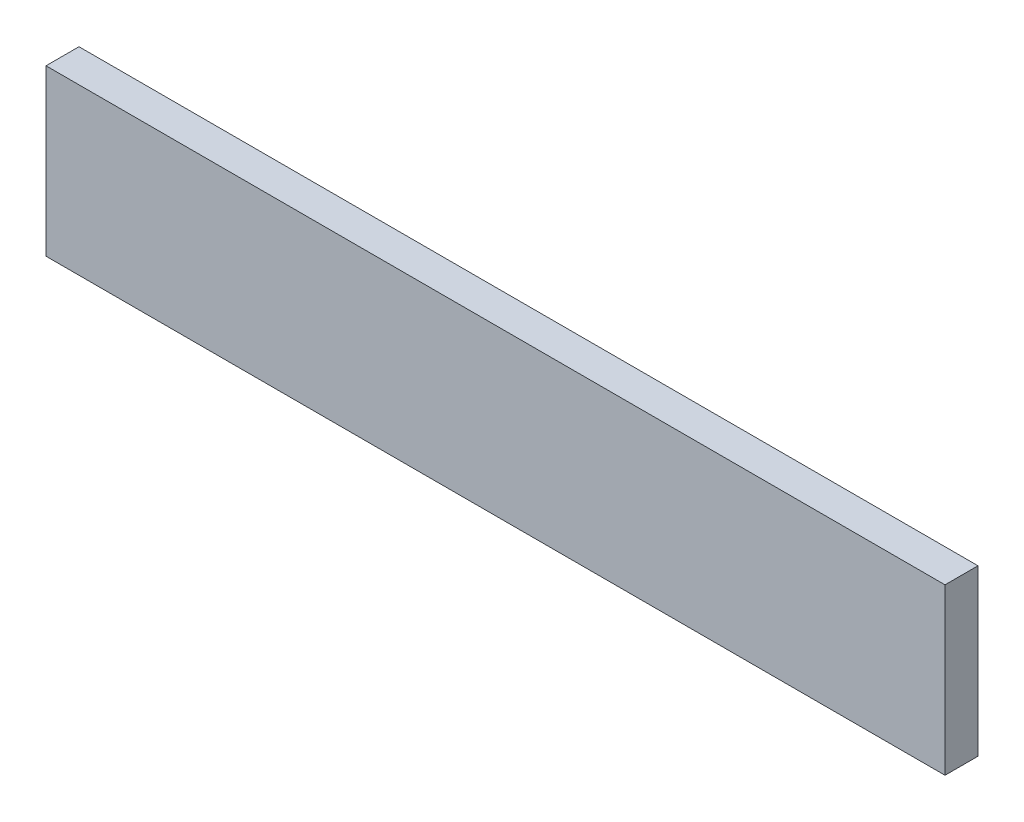
from build123d import *

# Parameters (mm, degrees)
SKETCH1_W           = 138.43
SKETCH1_H           = 25.4
BOSS_EXTRUDE1_DEPTH = 5.08


with BuildPart() as part:
    # Sketch1 → Boss-Extrude1 (new body)
    with BuildSketch(Plane.XY):
        with Locations((69.215, 12.7)):
            Rectangle(SKETCH1_W, SKETCH1_H)
    extrude(amount=BOSS_EXTRUDE1_DEPTH)


solid = part.part
